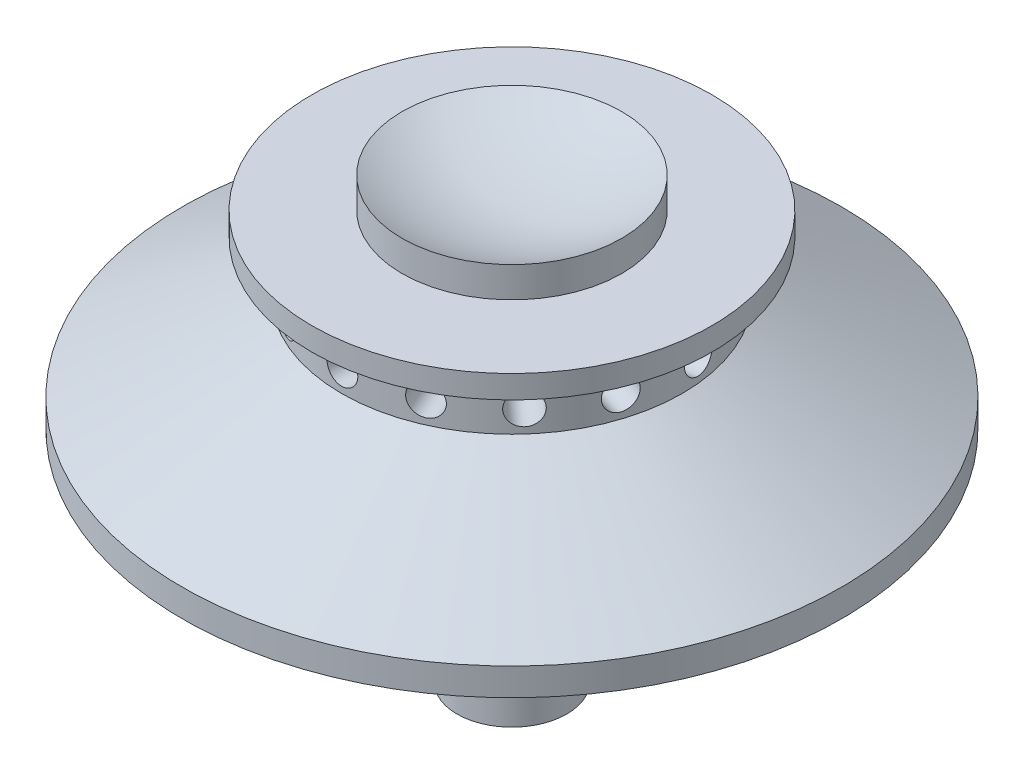
from build123d import *

# Parameters (mm, degrees)
CIRPATTERN1_COUNT = 15
SKETCH3_R         = 6.35
EXTRUDE1_DEPTH    = 25.4


with BuildPart() as part:
    # Sketch1 → Revolve1 (revolve)
    with BuildSketch(Plane.XY):
        with BuildLine():
            Line((0, 0), (-38.1, 0))
            Line((-38.1, 0), (-38.1, 3.175))
            Line((-38.1, 3.175), (-19.683026774, 13.355449774))
            Line((-19.683026774, 13.355449774), (-19.683026774, 19.225285171))
            Line((-19.683026774, 19.225285171), (-23.130794131, 19.225285171))
            Line((-23.130794131, 19.225285171), (-23.130794131, 21.874102239))
            Line((-23.130794131, 21.874102239), (-12.7, 21.874102239))
            Line((-12.7, 21.874102239), (-12.7, 25.4))
            ThreePointArc((-12.7, 25.4), (-6.545430181, 23.030779277), (0, 22.225))
            Line((0, 22.225), (0, 0))
        make_face()
    revolve(axis=Axis((0, 22.225, 0), (0, 1, 0)))

    # Sketch2 → 9/64 (0.14063) Diameter Hole1 (revolve, cut)
    with BuildSketch(Plane(origin=(0, 15.875, 19.683026774), x_dir=(0, -1, 0), z_dir=(1, 0, 0))):
        Polygon((0, 0), (0, 13.773137666), (1.786001, 12.7), (1.786001, 0), align=None)
    f_9_64_0_14063_diameter_hole1 = revolve(axis=Axis((0, 15.875, 26.033026774), (0, 0, -1)), mode=Mode.SUBTRACT)

    # CirPattern1: 9/64 (0.14063) Diameter Hole1 ×15 about axis
    cirpattern1_axis = Axis((0, 22.225, 0), (0, 1, 0))
    for i in range(1, CIRPATTERN1_COUNT):
        add(f_9_64_0_14063_diameter_hole1.rotate(cirpattern1_axis, i * 360 / CIRPATTERN1_COUNT), mode=Mode.SUBTRACT)

    # Sketch3 → Extrude1 (add)
    with BuildSketch(Plane.XZ):
        Circle(SKETCH3_R)
    extrude(amount=EXTRUDE1_DEPTH)


solid = part.part
